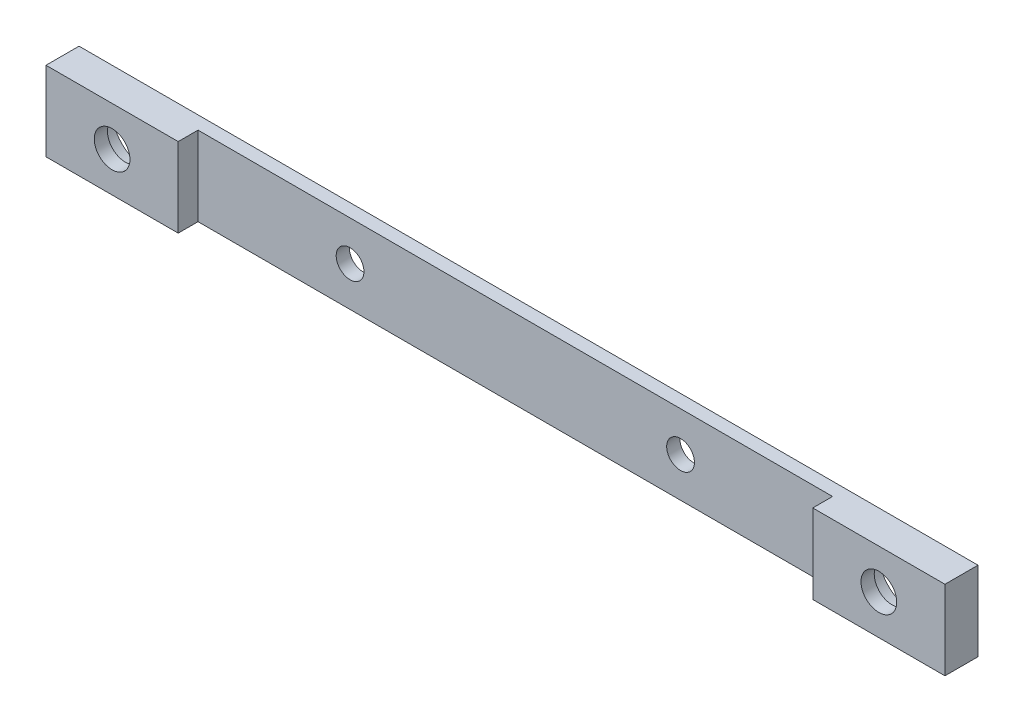
from build123d import *

# Parameters (mm, degrees)
SKETCH1_W           = 136
SKETCH1_H           = 12
SKETCH1_R           = 2.1
SKETCH1_R_2         = 5
SKETCH1_R_3         = 2.7
BOSS_EXTRUDE1_DEPTH = 5
SKETCH2_W           = 96
SKETCH2_H           = 3
CUT_EXTRUDE1_DEPTH  = 12
SKETCH1_3_R         = 5
CUT_EXTRUDE2_DEPTH  = 3


with BuildPart() as part:
    # Sketch1 → Boss-Extrude1 (new body)
    with BuildSketch(Plane.XY):
        Rectangle(SKETCH1_W, SKETCH1_H)
        with Locations((25, 0)):
            Circle(SKETCH1_R, mode=Mode.SUBTRACT)
        with Locations((-58, 0)):
            Circle(SKETCH1_R_2, mode=Mode.SUBTRACT)
        with Locations((-25, 0)):
            Circle(SKETCH1_R, mode=Mode.SUBTRACT)
        with Locations((58, 0)):
            Circle(SKETCH1_R_2, mode=Mode.SUBTRACT)
        with Locations((-58, 0)):
            Circle(SKETCH1_R_2)
        with Locations((-58, 0)):
            Circle(SKETCH1_R_3, mode=Mode.SUBTRACT)
        with Locations((58, 0)):
            Circle(SKETCH1_R_2)
        with Locations((58, 0)):
            Circle(SKETCH1_R_3, mode=Mode.SUBTRACT)
    extrude(amount=BOSS_EXTRUDE1_DEPTH)

    # Sketch2 → Cut-Extrude1 (cut)
    with BuildSketch(Plane.XZ.offset(6)):
        with Locations((0, 3.5)):
            Rectangle(SKETCH2_W, SKETCH2_H)
    extrude(amount=-CUT_EXTRUDE1_DEPTH, mode=Mode.SUBTRACT)

    # Sketch1_3 → Cut-Extrude2 (cut)
    with BuildSketch(Plane.XY):
        with Locations((-58, 0)):
            Circle(SKETCH1_3_R)
        with Locations((58, 0)):
            Circle(SKETCH1_3_R)
    extrude(amount=CUT_EXTRUDE2_DEPTH, mode=Mode.SUBTRACT)


solid = part.part
